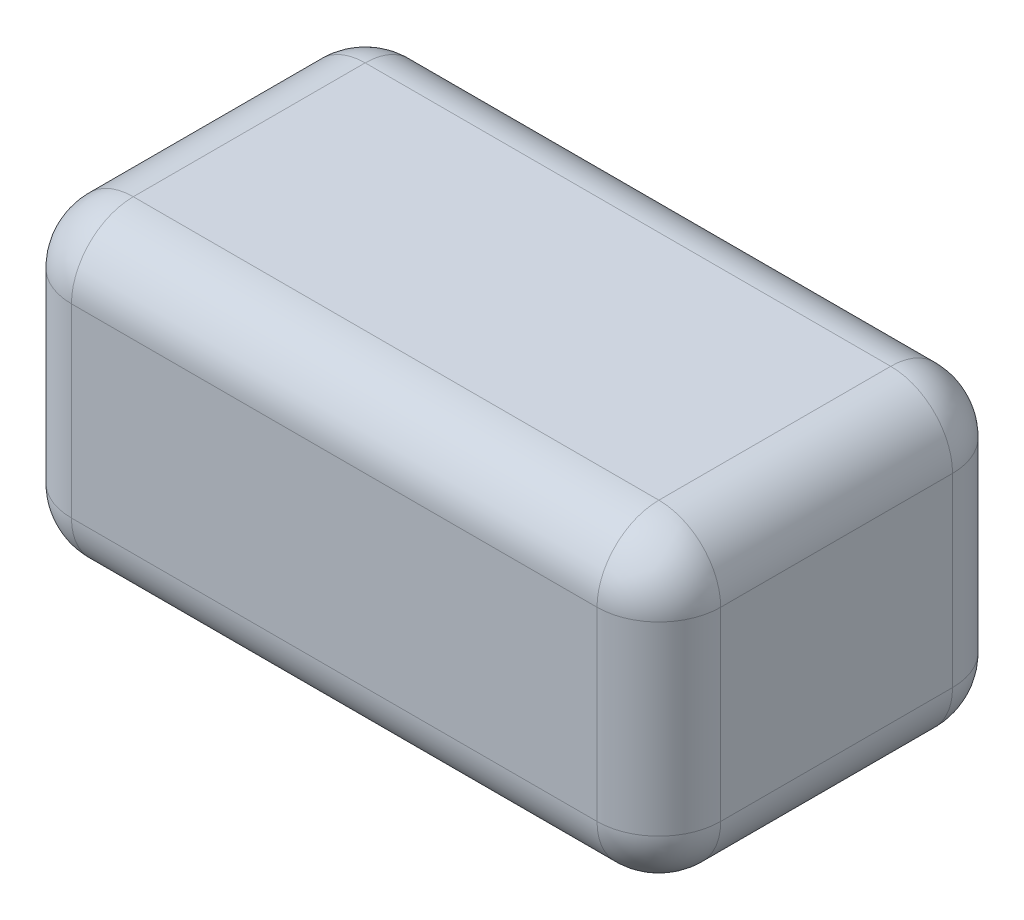
from build123d import *

# Parameters (mm, degrees)
SKETCH1_W           = 42
SKETCH1_H           = 23
BOSS_EXTRUDE1_DEPTH = 20
FILLET1_R           = 4


with BuildPart() as part:
    # Sketch1 → Boss-Extrude1 (new body)
    with BuildSketch(Plane(origin=(0, 0, 0), x_dir=(1, 0, 0), z_dir=(0, 1, 0))):
        with Locations((-19.115412049, -8.302704264)):
            Rectangle(SKETCH1_W, SKETCH1_H)
    extrude(amount=BOSS_EXTRUDE1_DEPTH)

    # Fillet1
    fillet1_edges = [part.edges().sort_by_distance(p)[0] for p in [
        (1.884587951, 20, 8.302704264),
        (-19.115412049, 20, -3.197295736),
        (-40.115412049, 20, 8.302704264),
        (-19.115412049, 0, -3.197295736),
        (1.884587951, 0, 8.302704264),
        (-19.115412049, 0, 19.802704264),
        (-40.115412049, 0, 8.302704264),
        (-19.115412049, 20, 19.802704264),
        (-40.115412049, 10, -3.197295736),
        (1.884587951, 10, -3.197295736),
        (1.884587951, 10, 19.802704264),
        (-40.115412049, 10, 19.802704264),
    ]]
    fillet(fillet1_edges, radius=FILLET1_R)


solid = part.part
